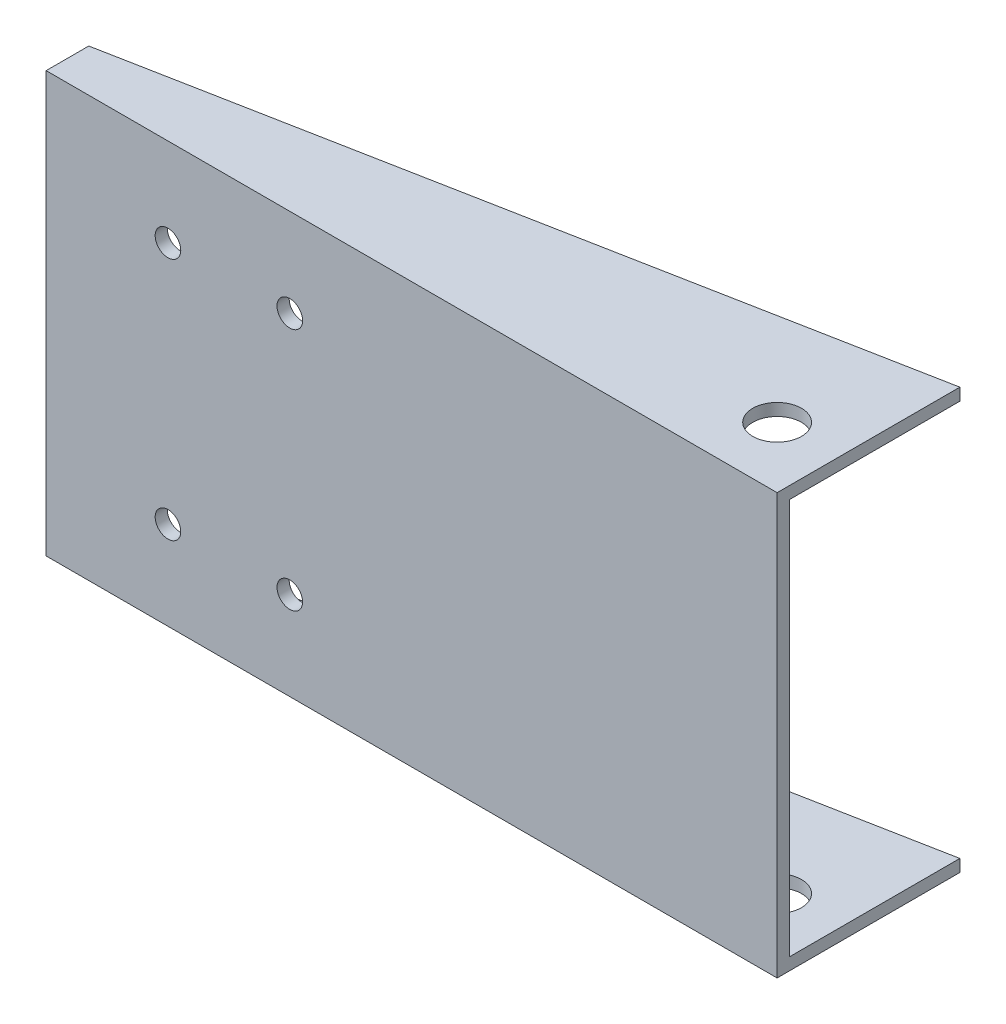
from build123d import *

# Parameters (mm, degrees)
SKETCH_1_W          = 120
SKETCH_1_H          = 65
EXTRUDE_1_DEPTH     = 2
EXTRUDE_2_DEPTH     = 2
SKETCH_3_R          = 2.1
CUT_EXTRUDE_1_DEPTH = 2
SKETCH_4_R          = 4
CUT_EXTRUDE_2_DEPTH = 70


with BuildPart() as part:
    # 草图1 → 凸台-拉伸1 (new body)
    with BuildSketch(Plane.XY):
        with Locations((24.994747839, 60.778264202)):
            Rectangle(SKETCH_1_W, SKETCH_1_H)
    extrude(amount=EXTRUDE_1_DEPTH)

    # 草图2 → 凸台-拉伸2 (add)
    with BuildSketch(Plane.XZ.offset(-28.278264202)):
        Polygon((-35.005252161, 2), (-35.005252161, 0), (-35.005252161, -5), (84.994747839, -28), (84.994747839, 2), align=None)
    extrude_2 = extrude(amount=EXTRUDE_2_DEPTH)

    # 镜向1: 凸台-拉伸2 across plane
    add(extrude_2.mirror(Plane.ZX.offset(60.778264202)))

    # 草图3 → 切除-拉伸1 (cut)
    with BuildSketch(Plane.XY.offset(2)):
        with Locations((-15.005252161, 80.778264202)):
            Circle(SKETCH_3_R)
        with Locations((4.994747839, 80.778264202)):
            Circle(SKETCH_3_R)
        with Locations((-15.005252161, 40.778264202)):
            Circle(SKETCH_3_R)
        with Locations((4.994747839, 40.778264202)):
            Circle(SKETCH_3_R)
    extrude(amount=-CUT_EXTRUDE_1_DEPTH, mode=Mode.SUBTRACT)

    # 草图4 → 切除-拉伸2 (cut)
    with BuildSketch(Plane(origin=(0, 26.278264202, 0), x_dir=(-1, 0, 0), z_dir=(0, -1, 0))):
        with Locations((-74.994747839, 8)):
            Circle(SKETCH_4_R)
    extrude(amount=-CUT_EXTRUDE_2_DEPTH, mode=Mode.SUBTRACT)


solid = part.part
